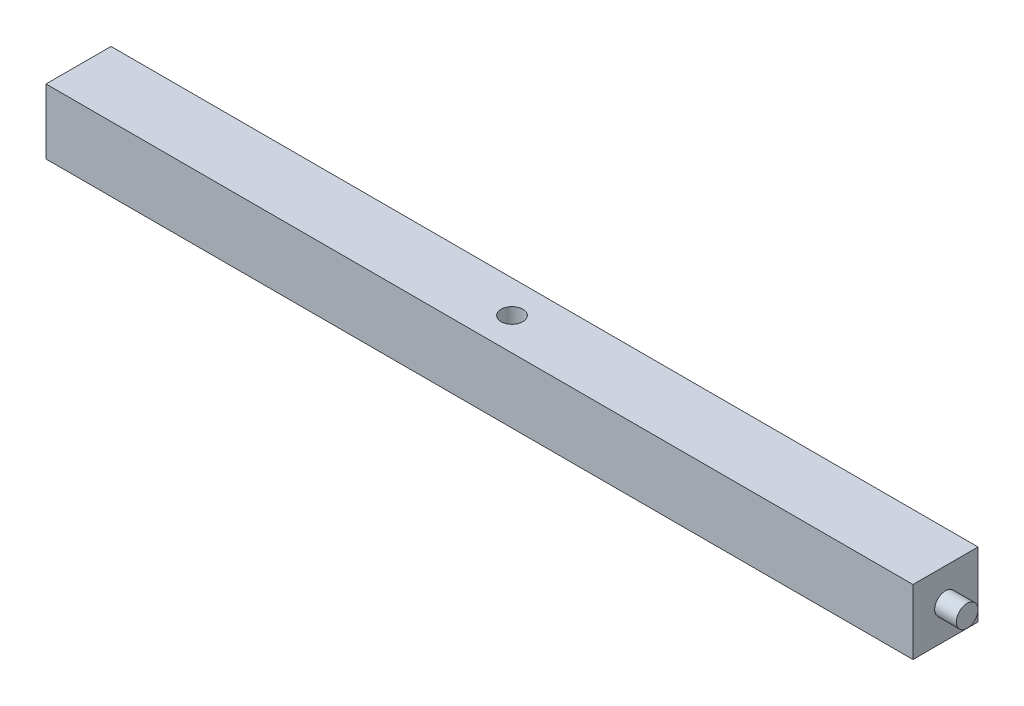
from build123d import *

# Parameters (mm, degrees)
CROQUIS1_W              = 508
CROQUIS1_H              = 38.1
SALIENTE_EXTRUIR1_DEPTH = 38.1
CROQUIS2_R              = 6.35
SALIENTE_EXTRUIR2_DEPTH = 12.7
CROQUIS3_R              = 6.35
SALIENTE_EXTRUIR3_DEPTH = 12.7
CROQUIS4_R              = 6.35
CORTAR_EXTRUIR1_DEPTH   = 12.7


with BuildPart() as part:
    # Croquis1 → Saliente-Extruir1 (new body)
    with BuildSketch(Plane(origin=(0, 0, 0), x_dir=(1, 0, 0), z_dir=(0, 1, 0))):
        Rectangle(CROQUIS1_W, CROQUIS1_H)
    extrude(amount=SALIENTE_EXTRUIR1_DEPTH)

    # Croquis2 → Saliente-Extruir2 (add)
    with BuildSketch(Plane.ZY.offset(254)):
        with Locations((0, 19.05)):
            Circle(CROQUIS2_R)
    extrude(amount=SALIENTE_EXTRUIR2_DEPTH)

    # Croquis3 → Saliente-Extruir3 (add)
    with BuildSketch(Plane(origin=(254, 0, 0), x_dir=(0, 0, -1), z_dir=(1, 0, 0))):
        with Locations((0, 19.05)):
            Circle(CROQUIS3_R)
    extrude(amount=SALIENTE_EXTRUIR3_DEPTH)

    # Croquis4 → Cortar-Extruir1 (cut)
    with BuildSketch(Plane(origin=(0, 38.1, 0), x_dir=(1, 0, 0), z_dir=(0, 1, 0))):
        Circle(CROQUIS4_R)
    extrude(amount=-CORTAR_EXTRUIR1_DEPTH, mode=Mode.SUBTRACT)


solid = part.part
